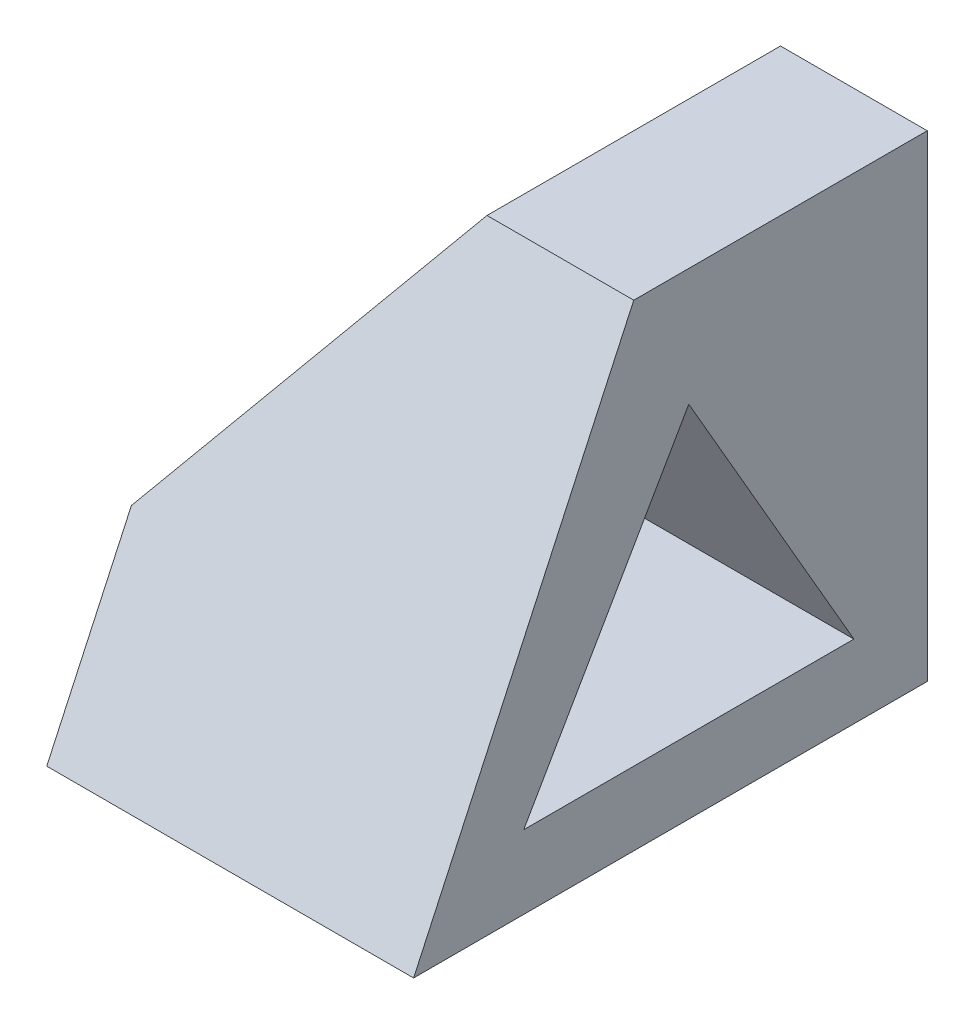
from build123d import *

# Parameters (mm, degrees)
EXTRUDE1_DEPTH     = 70
CUT_EXTRUDE1_DEPTH = 51


with BuildPart() as part:
    # Sketch1 → Extrude1 (new body)
    with BuildSketch(Plane.XY):
        Polygon((30, 65), (0, 25), (0, 0), (50, 0), (50, 65), align=None)
    extrude(amount=EXTRUDE1_DEPTH)

    # Sketch2 → Cut-Extrude1 (cut, through all)
    with BuildSketch(Plane(origin=(50, 0, 0), x_dir=(0, 0, -1), z_dir=(1, 0, 0))):
        Polygon((-70, 0), (-70, 65), (-40, 65), align=None)
        Polygon((-32.5, 48.97114317), (-10, 10), (-55, 10), align=None)
    extrude(amount=-CUT_EXTRUDE1_DEPTH, mode=Mode.SUBTRACT)


solid = part.part
